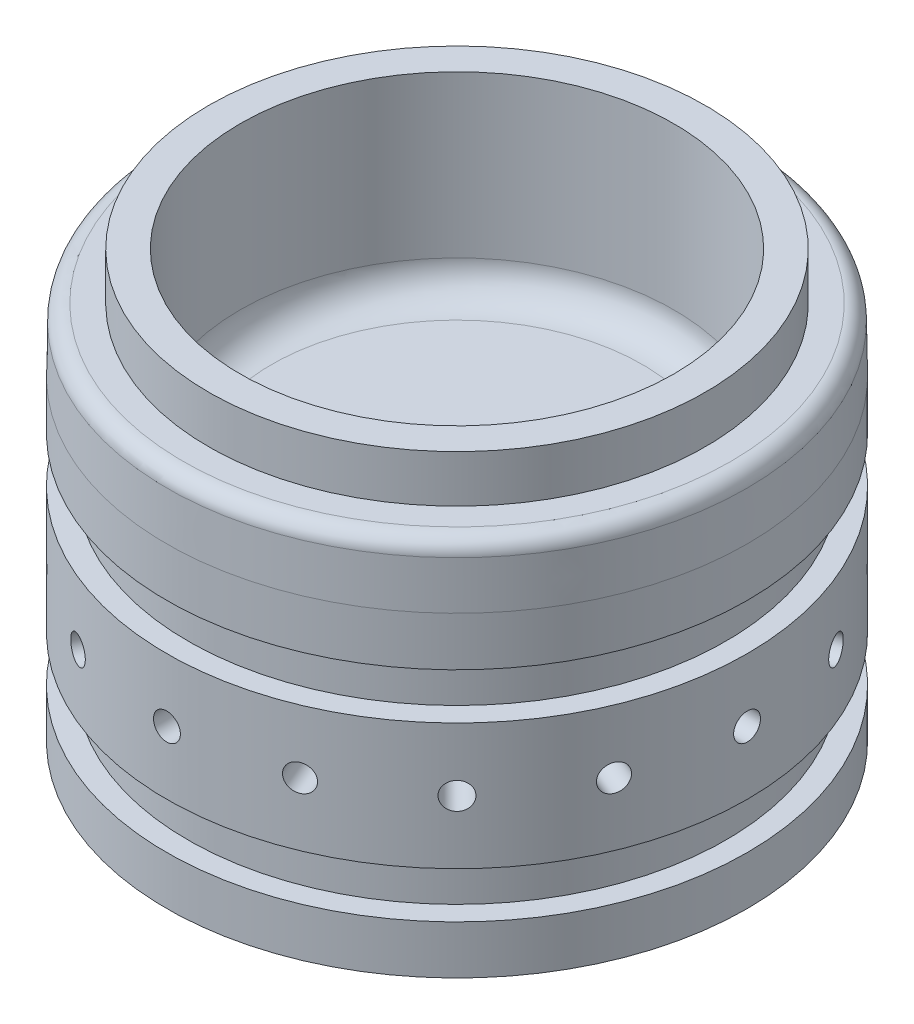
from build123d import *

# Parameters (mm, degrees)
TAPERFILLET_R                     = 3.175
HOLEPATTERN_COUNT                 = 16
POCKETFILLETS_R                   = 6.35
PIPE_TAP_DRILL_FOR_1_2_TAP1_D     = 17.8562
PIPE_TAP_DRILL_FOR_1_2_TAP1_DEPTH = 46.99
PIPE_TAP_DRILL_FOR_1_2_TAP1_TIP   = 5.364543693


with BuildPart() as part:
    # Sketch1 → Revolve1 (revolve)
    with BuildSketch(Plane.XY):
        Polygon((0, -15.24), (0, 0), (-58.4454, 0), (-58.4454, -12.7), (-54.1274, -12.7), (-54.1274, -21.971), (-58.4454, -21.971), (-58.4454, -31.75), (-48.9331, -31.75), (-48.9331, -15.24), align=None)
        Polygon((-58.4454, 0), (0, 0), (0, 15.24), (-43.6499, 15.24), (-43.6499, 54.0385), (-49.9999, 54.0385), (-49.9999, 44.5262), (-58.236420675, 44.5262), (-58.4454, 31.8262), (-58.4454, 21.971), (-54.1274, 21.971), (-54.1274, 12.7), (-58.4454, 12.7), align=None)
    revolve(axis=Axis((0, 31.75, 0), (0, -1, 0)))

    # TaperFillet
    taperfillet_edges = [part.edges().sort_by_distance(p)[0] for p in [
        (58.236420675, 44.5262, 0),
    ]]
    fillet(taperfillet_edges, radius=TAPERFILLET_R)

    # Sketch4 → Tap Drill for 1/4-28 Tap1 (revolve, cut)
    with BuildSketch(Plane(origin=(0, 0, -58.4454), x_dir=(0, 1, 0), z_dir=(1, 0, 0))):
        Polygon((0, 0), (0, 20.675388061), (2.7051, 19.05), (2.7051, 0), align=None)
    tap_drill_for_1_4_28_tap1 = revolve(axis=Axis((0, 0, -64.7954), (0, 0, 1)), mode=Mode.SUBTRACT)

    # HolePattern: Tap Drill for 1/4-28 Tap1 ×16 about axis
    holepattern_axis = Axis((0, -12.7, 0), (0, 1, 0))
    for i in range(1, HOLEPATTERN_COUNT):
        add(tap_drill_for_1_4_28_tap1.rotate(holepattern_axis, i * 360 / HOLEPATTERN_COUNT), mode=Mode.SUBTRACT)

    # PocketFillets
    pocketfillets_edges = [part.edges().sort_by_distance(p)[0] for p in [
        (43.6499, 15.24, 0),
        (48.9331, -15.24, 0),
    ]]
    fillet(pocketfillets_edges, radius=POCKETFILLETS_R)

    # Pipe Tap Drill for 1/2 Tap1
    with Locations(Plane(origin=(0, 15.24, 0), x_dir=(1, 0, 0), z_dir=(0, 1, 0))):
        with Locations((0, 0)):
            Hole(PIPE_TAP_DRILL_FOR_1_2_TAP1_D / 2, depth=PIPE_TAP_DRILL_FOR_1_2_TAP1_DEPTH)
            with Locations((0, 0, -(PIPE_TAP_DRILL_FOR_1_2_TAP1_DEPTH + PIPE_TAP_DRILL_FOR_1_2_TAP1_TIP / 2))):  # 118° drill point
                Cone(0, PIPE_TAP_DRILL_FOR_1_2_TAP1_D / 2, PIPE_TAP_DRILL_FOR_1_2_TAP1_TIP, mode=Mode.SUBTRACT)


solid = part.part
